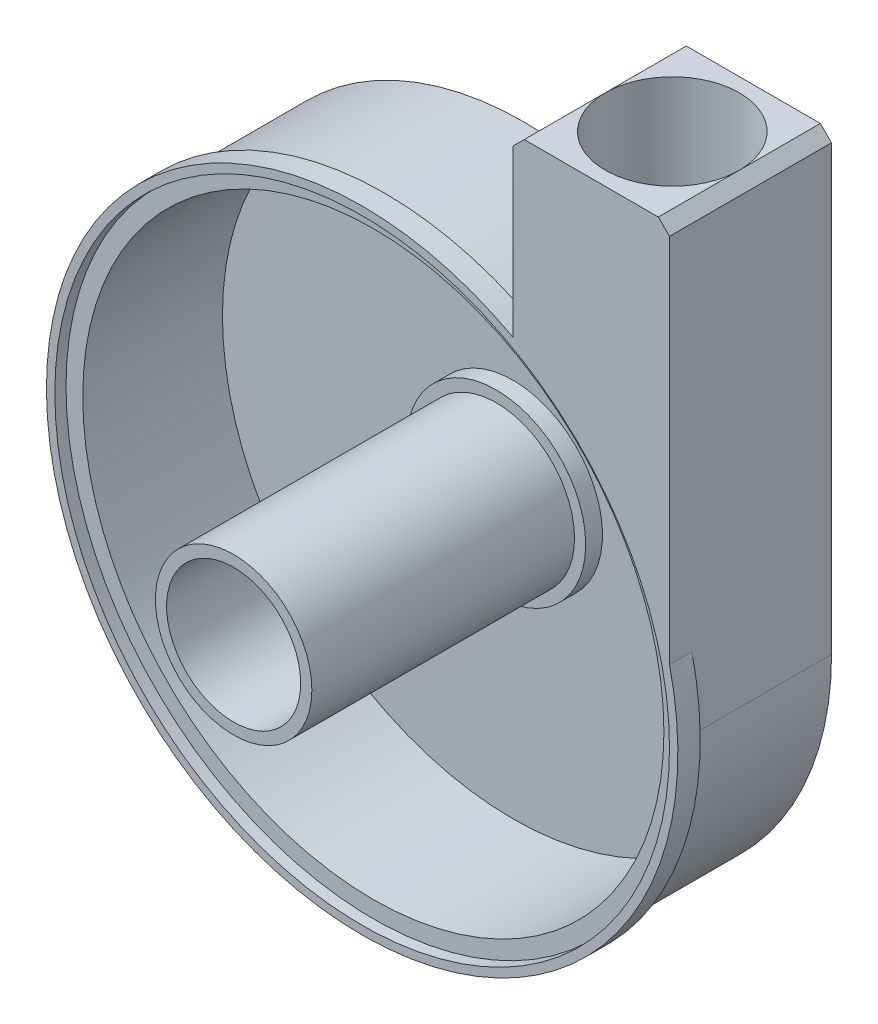
from build123d import *
from build123d.topology import SkipClean

# Parameters (mm, degrees)
SKETCH1_R           = 55
SKETCH1_R_2         = 52
BOSS_EXTRUDE1_DEPTH = 25
BOSS_EXTRUDE2_START = -27
BOSS_EXTRUDE2_DEPTH = 29
BOSS_EXTRUDE3_START = 2
SKETCH5_R           = 55
SKETCH5_R_2         = 12
BOSS_EXTRUDE3_DEPTH = 2
SKETCH6_R           = 14
SKETCH6_R_2         = 12.000000000000002
BOSS_EXTRUDE4_DEPTH = 50
SKETCH7_R           = 16
SKETCH7_R_2         = 14.000000000000002
BOSS_EXTRUDE5_DEPTH = 3
BOSS_EXTRUDE6_START = -2
SKETCH8_R           = 55
SKETCH8_R_2         = 52
BOSS_EXTRUDE6_DEPTH = 2
SKETCH9_R           = 11.999999999999996
CUT_EXTRUDE1_DEPTH  = 80.00000000000001
CHAMFER1_SIZE       = 2
BOSS_EXTRUDE8_START = -2
SKETCH11_R          = 56.5
SKETCH11_R_2        = 54.99999999999999
BOSS_EXTRUDE8_DEPTH = 4


with BuildPart() as part:
    # Sketch1 → Boss-Extrude1 (new body)
    with BuildSketch(Plane.XY):
        Circle(SKETCH1_R)
        Circle(SKETCH1_R_2, mode=Mode.SUBTRACT)
    extrude(amount=BOSS_EXTRUDE1_DEPTH)

    # Sketch2 → Boss-Extrude2 (add)
    with BuildSketch(Plane.XY.offset(25).offset(BOSS_EXTRUDE2_START)):
        with BuildLine():
            Line((27, 81.28713256522299), (27, 47.91659420284375))
            ThreePointArc((27, 47.91659420284375), (47.486840282335066, 27.74887385102322), (55, 0))
            Line((55, 0), (55, 81.28713256522299))
            Line((55, 81.28713256522299), (27, 81.28713256522299))
        make_face()
    extrude(amount=BOSS_EXTRUDE2_DEPTH)

    # Sketch5 → Boss-Extrude3 (add)
    with BuildSketch(Plane(origin=(0, 0, 0), x_dir=(-1, 0, 0), z_dir=(0, 0, -1)).offset(BOSS_EXTRUDE3_START)):
        Circle(SKETCH5_R)
        Circle(SKETCH5_R_2, mode=Mode.SUBTRACT)
    extrude(amount=-BOSS_EXTRUDE3_DEPTH)

    # Sketch6 → Boss-Extrude4 (add)
    with BuildSketch(Plane.XY):
        with Locations(Location((0, 0, 0), (0, 0, 180))):
            Circle(SKETCH6_R)
        Circle(SKETCH6_R_2, mode=Mode.SUBTRACT)
    extrude(amount=BOSS_EXTRUDE4_DEPTH)

    # Sketch7 → Boss-Extrude5 (add)
    with BuildSketch(Plane.XY):
        with Locations(Location((0, 0, 0), (0, 0, 180))):
            Circle(SKETCH7_R)
        Circle(SKETCH7_R_2, mode=Mode.SUBTRACT)
    extrude(amount=BOSS_EXTRUDE5_DEPTH)

    # Sketch8 → Boss-Extrude6 (add)
    with BuildSketch(Plane.XY.offset(25).offset(BOSS_EXTRUDE6_START)):
        Circle(SKETCH8_R)
        Circle(SKETCH8_R_2, mode=Mode.SUBTRACT)
    extrude(amount=BOSS_EXTRUDE6_DEPTH)

    # Sketch9 → Cut-Extrude1 (cut)
    with BuildSketch(Plane(origin=(0, 81.28713256522299, 0), x_dir=(1, 0, 0), z_dir=(0, 1, 0))):
        with Locations(Location((41, -12.5, 0), (0, 0, 270))):
            Circle(SKETCH9_R)
    extrude(amount=-CUT_EXTRUDE1_DEPTH, mode=Mode.SUBTRACT)

    # Chamfer1
    chamfer1_edges = [part.edges().sort_by_distance(p)[0] for p in [
        (55, 81.28713256522299, 12.5),
        (27, 81.28713256522299, 12.5),
    ]]
    chamfer(chamfer1_edges, length=CHAMFER1_SIZE)

    # Sketch11 → Boss-Extrude8 (add)
    with SkipClean():  # the faces are left unmerged after this step: merging them gives an invalid solid
        with BuildSketch(Plane.XY.offset(25).offset(BOSS_EXTRUDE8_START)):
            Circle(SKETCH11_R)
            Circle(SKETCH11_R_2, mode=Mode.SUBTRACT)
        extrude(amount=BOSS_EXTRUDE8_DEPTH)


solid = part.part
